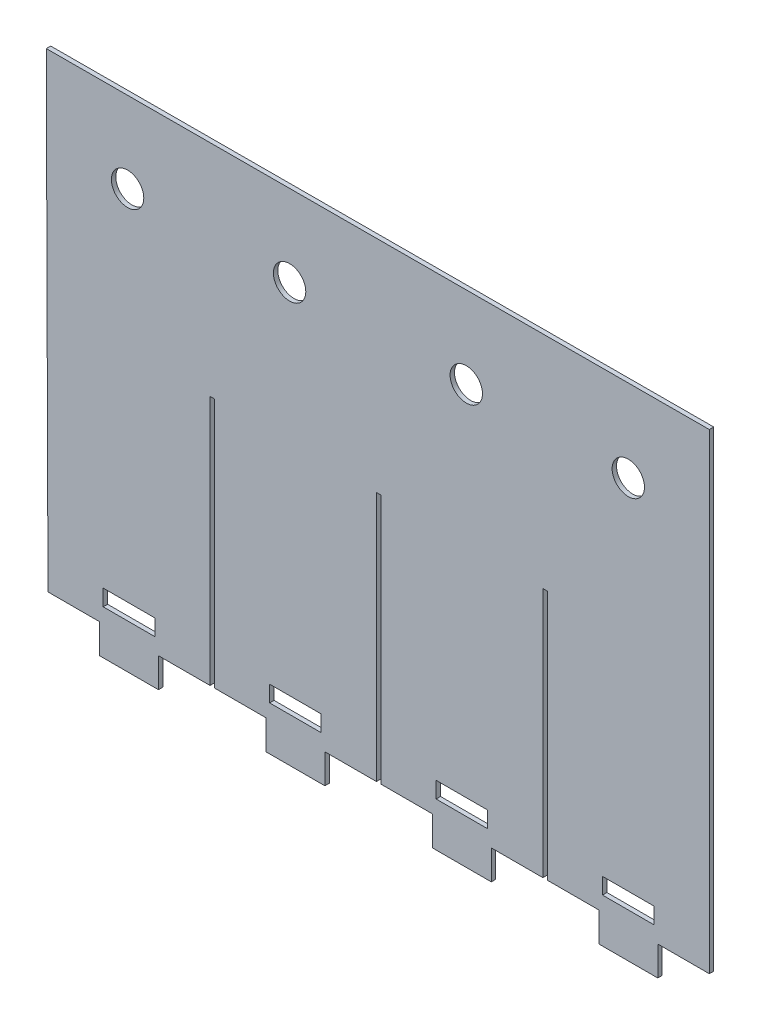
from build123d import *

# Parameters (mm, degrees)
BOSS_EXTRUDE1_DEPTH = 3
SKETCH2_R           = 11
CUT_EXTRUDE1_DEPTH  = 3
SKETCH3_W           = 35
SKETCH3_H           = 11
CUT_EXTRUDE2_DEPTH  = 3


with BuildPart() as part:
    # Sketch1 → Boss-Extrude1 (new body)
    with BuildSketch(Plane.XY):
        Polygon((450.167740667, -318.916738079), (450.167740667, 1.083261921), (0, 0), (1.167740667, -318.916738079), (36.167740667, -318.916738079), (36.167740667, -338.916738079), (76.167740667, -338.916738079), (76.167740667, -318.916738079), (111.167740667, -318.916738079), (111.167740667, -148.916738079), (114.167740667, -148.916738079), (114.167740667, -318.916738079), (149.167740667, -318.916738079), (149.167740667, -338.916738079), (189.167740667, -338.916738079), (189.167740667, -318.916738079), (224.167740667, -318.916738079), (224.167740667, -148.916738079), (227.167740667, -148.916738079), (227.167740667, -318.916738079), (262.167740667, -318.916738079), (262.167740667, -338.916738079), (302.167740667, -338.916738079), (302.167740667, -318.916738079), (337.167740667, -318.916738079), (337.167740667, -148.916738079), (340.167740667, -148.916738079), (340.167740667, -318.916738079), (375.167740667, -318.916738079), (375.167740667, -338.916738079), (415.167740667, -338.916738079), (415.167740667, -318.916738079), align=None)
    extrude(amount=BOSS_EXTRUDE1_DEPTH)

    # Sketch2 → Cut-Extrude1 (cut)
    with BuildSketch(Plane.XY.offset(3)):
        with Locations((55.20127006, -54.867325568)):
            Circle(SKETCH2_R)
        with Locations((165.20127006, -54.867325568)):
            Circle(SKETCH2_R)
        with Locations((285.167740667, -54.867325568)):
            Circle(SKETCH2_R)
        with Locations((395.167740667, -54.867325568)):
            Circle(SKETCH2_R)
    extrude(amount=-CUT_EXTRUDE1_DEPTH, mode=Mode.SUBTRACT)

    # Sketch3 → Cut-Extrude2 (cut)
    with BuildSketch(Plane.XY.offset(3)):
        with Locations((395.167740667, -303.416738079)):
            Rectangle(SKETCH3_W, SKETCH3_H)
        with Locations((169.167740667, -303.416738079)):
            Rectangle(SKETCH3_W, SKETCH3_H)
        with Locations((282.167740667, -303.416738079)):
            Rectangle(SKETCH3_W, SKETCH3_H)
        with Locations((56.167740667, -303.416738079)):
            Rectangle(SKETCH3_W, SKETCH3_H)
    extrude(amount=-CUT_EXTRUDE2_DEPTH, mode=Mode.SUBTRACT)


solid = part.part
